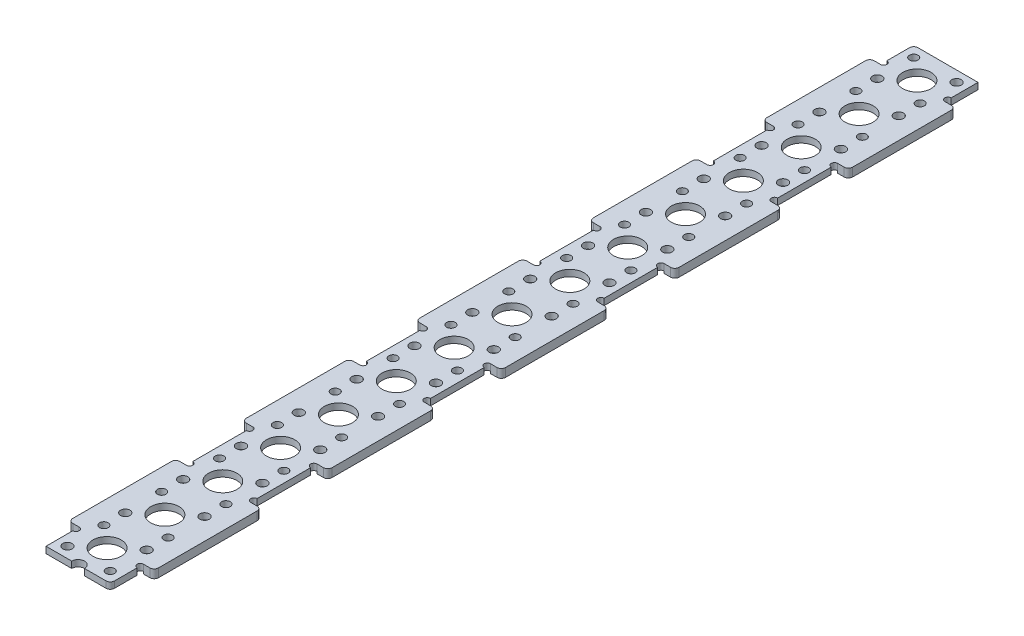
from build123d import *

# Parameters (mm, degrees)
SKETCH_4_W             = 15
SKETCH_4_H             = 202.5
SKETCH_4_R             = 3.3
EXTRUDE_1_DEPTH        = 0.75
SKETCH_2_R             = 1
SKETCH_2_R_2           = 1.1
CUT_EXTRUDE_1_DEPTH    = 1.75
PATTERN_LINEAR_1_COUNT = 15
PATTERN_LINEAR_1_PITCH = 13.5
SKETCH_5_R             = 1.5
CUT_EXTRUDE_2_DEPTH    = 2.5
EXTRUDE_2_DEPTH        = 2
SKETCH_7_R             = 0.75
CUT_EXTRUDE_3_DEPTH    = 3
PATTERN_LINEAR_2_COUNT = 5
PATTERN_LINEAR_2_PITCH = 40.5
FILLET_1_R             = 1


with BuildPart() as part:
    # 草图4 → 凸台-拉伸1 (new body, symmetric)
    with BuildSketch(Plane(origin=(0, 0, 0), x_dir=(1, 0, 0), z_dir=(0, 1, 0))):
        with Locations((0, 94.5)):
            Rectangle(SKETCH_4_W, SKETCH_4_H)
        with Locations((0, 13.5)):
            Circle(SKETCH_4_R, mode=Mode.SUBTRACT)
        Circle(SKETCH_4_R, mode=Mode.SUBTRACT)
        with Locations((0, 27)):
            Circle(SKETCH_4_R, mode=Mode.SUBTRACT)
        with Locations((0, 40.5)):
            Circle(SKETCH_4_R, mode=Mode.SUBTRACT)
        with Locations((0, 54)):
            Circle(SKETCH_4_R, mode=Mode.SUBTRACT)
        with Locations((0, 67.5)):
            Circle(SKETCH_4_R, mode=Mode.SUBTRACT)
        with Locations((0, 81)):
            Circle(SKETCH_4_R, mode=Mode.SUBTRACT)
        with Locations((0, 94.5)):
            Circle(SKETCH_4_R, mode=Mode.SUBTRACT)
        with Locations((0, 108)):
            Circle(SKETCH_4_R, mode=Mode.SUBTRACT)
        with Locations((0, 121.5)):
            Circle(SKETCH_4_R, mode=Mode.SUBTRACT)
        with Locations((0, 135)):
            Circle(SKETCH_4_R, mode=Mode.SUBTRACT)
        with Locations((0, 148.5)):
            Circle(SKETCH_4_R, mode=Mode.SUBTRACT)
        with Locations((0, 162)):
            Circle(SKETCH_4_R, mode=Mode.SUBTRACT)
        with Locations((0, 175.5)):
            Circle(SKETCH_4_R, mode=Mode.SUBTRACT)
        with Locations((0, 189)):
            Circle(SKETCH_4_R, mode=Mode.SUBTRACT)
    extrude(amount=EXTRUDE_1_DEPTH, both=True)

    # 草图2 → 切除-拉伸1 (cut, symmetric)
    with BuildSketch(Plane(origin=(0, 0, 0), x_dir=(1, 0, 0), z_dir=(0, 1, 0))):
        with Locations((-5, 4.25)):
            Circle(SKETCH_2_R)
        with Locations((-5, -4.25)):
            Circle(SKETCH_2_R_2)
        with Locations((5, -4.25)):
            Circle(SKETCH_2_R)
        with Locations((5, 4.25)):
            Circle(SKETCH_2_R_2)
    cut_extrude_1 = extrude(amount=CUT_EXTRUDE_1_DEPTH, both=True, mode=Mode.SUBTRACT)

    # 阵列(线性)1: 切除-拉伸1 ×15
    with Locations(*[(0, 0, -i * PATTERN_LINEAR_1_PITCH) for i in range(1, PATTERN_LINEAR_1_COUNT)]):
        add(cut_extrude_1, mode=Mode.SUBTRACT)

    # 草图5 → 切除-拉伸2 (cut, through all)
    with BuildSketch(Plane(origin=(0, 0.75, 0), x_dir=(1, 0, 0), z_dir=(0, 1, 0))):
        with Locations((0, -6.75)):
            Circle(SKETCH_5_R)
    extrude(amount=-CUT_EXTRUDE_2_DEPTH, mode=Mode.SUBTRACT)

    # 草图6 → 凸台-拉伸2 (add)
    with BuildSketch(Plane(origin=(0, 0.75, 0), x_dir=(1, 0, 0), z_dir=(0, 1, 0))):
        with BuildLine():
            Line((-7.5, 1), (-9, 1))
            ThreePointArc((-9, 1), (-9.707106781, 1.292893219), (-10, 2))
            Line((-10, 2), (-10, 25))
            ThreePointArc((-10, 25), (-9.707106781, 25.707106781), (-9, 26))
            Line((-9, 26), (-7.5, 26))
            Line((-7.5, 26), (-7.5, 1))
        make_face()
        with BuildLine():
            Line((7.5, 26), (9, 26))
            ThreePointArc((9, 26), (9.707106781, 25.707106781), (10, 25))
            Line((10, 25), (10, 2))
            ThreePointArc((10, 2), (9.707106781, 1.292893219), (9, 1))
            Line((9, 1), (7.5, 1))
            Line((7.5, 1), (7.5, 26))
        make_face()
    extrude_2 = extrude(amount=-EXTRUDE_2_DEPTH)

    # 草图7 → 切除-拉伸3 (cut, through all)
    with BuildSketch(Plane(origin=(0, 0.75, 0), x_dir=(1, 0, 0), z_dir=(0, 1, 0))):
        with Locations((-7.5, 26.75)):
            Circle(SKETCH_7_R)
        with Locations((-7.5, 0.25)):
            Circle(SKETCH_7_R)
        with Locations((7.5, 0.25)):
            Circle(SKETCH_7_R)
        with Locations((7.5, 26.75)):
            Circle(SKETCH_7_R)
    cut_extrude_3 = extrude(amount=-CUT_EXTRUDE_3_DEPTH, mode=Mode.SUBTRACT)

    # 阵列(线性)2: 凸台-拉伸2, 切除-拉伸3 ×5
    with Locations(*[(0, 0, -i * PATTERN_LINEAR_2_PITCH) for i in range(1, PATTERN_LINEAR_2_COUNT)]):
        add(extrude_2)
        add(cut_extrude_3, mode=Mode.SUBTRACT)

    # 圆角1
    fillet_1_edges = [part.edges().sort_by_distance(p)[0] for p in [
        (7.5, 0, 6.75),
        (-7.5, 0, -195.75),
    ]]
    fillet(fillet_1_edges, radius=FILLET_1_R)


solid = part.part
